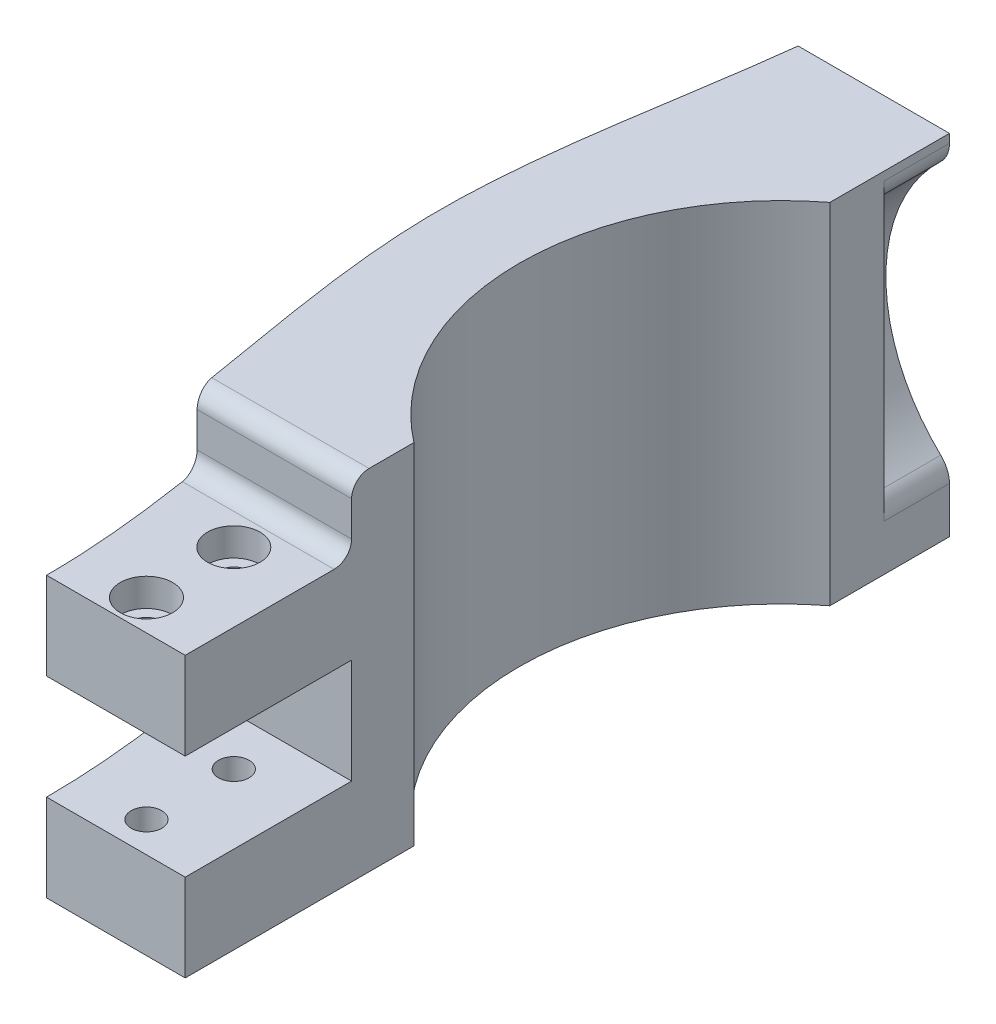
from build123d import *

# Parameters (mm, degrees)
BOSS_EXTRUDE1_DEPTH = 40
SKETCH3_W           = 12.7
SKETCH3_H           = 40
BOSS_EXTRUDE2_DEPTH = 27.178
SKETCH4_W           = 184.978795618
SKETCH4_H           = 131.733859804
CUT_EXTRUDE2_DEPTH  = 51
SKETCH5_W           = 144.166334374
SKETCH5_H           = 140.012963834
CUT_EXTRUDE3_DEPTH  = 18.25
SKETCH6_R           = 20
CUT_EXTRUDE4_DEPTH  = 20
FILLET4_R           = 3.175
SKETCH7_W           = 96.652193462
SKETCH7_H           = 93.586405028
CUT_EXTRUDE5_DEPTH  = 27.178
CUT_EXTRUDE6_DEPTH  = 41
CUT_EXTRUDE7_DEPTH  = 8
FILLET5_R           = 2
SKETCH10_R          = 1.75
CUT_EXTRUDE8_DEPTH  = 33.0000001
SKETCH11_W          = 9.551786503
SKETCH11_H          = 12
SKETCH11_W_2        = 7.9375
CUT_EXTRUDE9_DEPTH  = 19.05
SKETCH14_R          = 3
CUT_EXTRUDE10_DEPTH = 3.2
SKETCH15_W          = 61.098487026
SKETCH15_H          = 49.743772834
CUT_EXTRUDE11_DEPTH = 12.5


with BuildPart() as part:
    # Sketch1 → Boss-Extrude1 (new body)
    with BuildSketch(Plane(origin=(0, 0, 0), x_dir=(1, 0, 0), z_dir=(0, 1, 0))):
        with BuildLine():
            Line((-50, -50), (0, -50))
            Line((0, -50), (0, -30))
            ThreePointArc((0, -30), (-30, 0), (0, 30))
            Line((0, 30), (0, 50))
            Line((0, 50), (-50, 50))
            Line((-50, 50), (-50, -50))
        make_face()
        with BuildLine():
            Line((0, -30), (0, -50))
            Line((0, -50), (50, -50))
            Line((50, -50), (50, 50))
            Line((50, 50), (0, 50))
            Line((0, 50), (0, 30))
            ThreePointArc((0, 30), (21.213203436, 21.213203436), (30, 0))
            ThreePointArc((30, 0), (21.213203436, -21.213203436), (0, -30))
        make_face()
    extrude(amount=BOSS_EXTRUDE1_DEPTH)

    # Sketch3 → Boss-Extrude2 (add)
    with BuildSketch(Plane.XY.offset(50)):
        with Locations((-24.6, 20)):
            Rectangle(SKETCH3_W, SKETCH3_H)
    extrude(amount=BOSS_EXTRUDE2_DEPTH)

    # Sketch4 → Cut-Extrude2 (cut, through all)
    with BuildSketch(Plane(origin=(0, 0, 0), x_dir=(0, 0, -1), z_dir=(1, 0, 0))):
        Rectangle(SKETCH4_W, SKETCH4_H)
    extrude(amount=CUT_EXTRUDE2_DEPTH, mode=Mode.SUBTRACT)

    # Sketch5 → Cut-Extrude3 (cut)
    with BuildSketch(Plane(origin=(0, 0, 0), x_dir=(0, 0, -1), z_dir=(1, 0, 0))):
        Rectangle(SKETCH5_W, SKETCH5_H)
    extrude(amount=-CUT_EXTRUDE3_DEPTH, mode=Mode.SUBTRACT)

    # Sketch6 → Cut-Extrude4 (cut)
    with BuildSketch(Plane(origin=(0, 0, -50), x_dir=(-1, 0, 0), z_dir=(0, 0, -1))):
        with Locations((5.529693955, 22.14995336)):
            Circle(SKETCH6_R)
    extrude(amount=-CUT_EXTRUDE4_DEPTH, mode=Mode.SUBTRACT)

    # Fillet4
    fillet4_edges = [part.edges().sort_by_distance(p)[0] for p in [
        (-18.25, 6.716424466, -40),
        (-18.25, 37.583482255, -40),
    ]]
    fillet(fillet4_edges, radius=FILLET4_R)

    # Sketch7 → Cut-Extrude5 (cut)
    with BuildSketch(Plane.XY.offset(77.178)):
        Rectangle(SKETCH7_W, SKETCH7_H)
    extrude(amount=-CUT_EXTRUDE5_DEPTH, mode=Mode.SUBTRACT)

    # Sketch8 → Cut-Extrude6 (cut, through all)
    with BuildSketch(Plane(origin=(0, 40, 0), x_dir=(1, 0, 0), z_dir=(0, 1, 0))):
        with BuildLine():
            Line((-34.76, 50), (-50, 50))
            Line((-50, 50), (-50, -50))
            Line((-50, -50), (-34.125, -50))
            add(Edge.make_bspline(
                [(-34.125, -50), (-34.125, -33.241229213), (-45.237036485, -0.093705418), (-34.76, 33.330216103), (-34.76, 50)],
                knots=[0, 0, 0, 0, 0.500369617, 1, 1, 1, 1], degree=3))
        make_face()
    extrude(amount=-CUT_EXTRUDE6_DEPTH, mode=Mode.SUBTRACT)

    # Sketch9 → Cut-Extrude7 (cut)
    with BuildSketch(Plane(origin=(0, 40, 0), x_dir=(1, 0, 0), z_dir=(0, 1, 0))):
        with BuildLine():
            Line((-18.25, -50), (-18.25, -30.95))
            Line((-18.25, -30.95), (-35.932995014, -30.95))
            add(Edge.make_bspline(
                [(-34.125, -50), (-34.125, -43.629466822), (-34.928437006, -37.283896996), (-35.932995014, -30.95)],
                knots=[0, 0, 0, 0, 0.190206149, 0.190206149, 0.190206149, 0.190206149], degree=3))
            Line((-34.125, -50), (-18.25, -50))
        make_face()
    extrude(amount=-CUT_EXTRUDE7_DEPTH, mode=Mode.SUBTRACT)

    # Fillet5
    fillet5_edges = [part.edges().sort_by_distance(p)[0] for p in [
        (-27.091497507, 32, 30.95),
        (-27.091497507, 40, 30.95),
    ]]
    fillet(fillet5_edges, radius=FILLET5_R)

    # Sketch10 → Cut-Extrude8 (cut, through all)
    with BuildSketch(Plane(origin=(0, 32, 0), x_dir=(1, 0, 0), z_dir=(0, 1, 0))):
        with Locations((-26.1875, -46.5)):
            Circle(SKETCH10_R)
        with Locations((-26.1875, -36.5)):
            Circle(SKETCH10_R)
    extrude(amount=-CUT_EXTRUDE8_DEPTH, mode=Mode.SUBTRACT)

    # Sketch11 → Cut-Extrude9 (cut)
    with BuildSketch(Plane.XY.offset(50)):
        with Locations((-38.900893252, 16)):
            Rectangle(SKETCH11_W, SKETCH11_H)
        with Locations((-30.15625, 16)):
            Rectangle(SKETCH11_W_2, SKETCH11_H)
        with Locations((-22.21875, 16)):
            Rectangle(SKETCH11_W_2, SKETCH11_H)
    extrude(amount=-CUT_EXTRUDE9_DEPTH, mode=Mode.SUBTRACT)

    # Sketch14 → Cut-Extrude10 (cut)
    with BuildSketch(Plane(origin=(0, 32, 0), x_dir=(1, 0, 0), z_dir=(0, 1, 0))):
        with Locations((-26.1875, -36.5)):
            Circle(SKETCH14_R)
        with Locations((-26.1875, -46.5)):
            Circle(SKETCH14_R)
    cut_extrude10 = extrude(amount=-CUT_EXTRUDE10_DEPTH, mode=Mode.SUBTRACT)

    # Mirror2: Cut-Extrude10 across plane
    add(cut_extrude10.mirror(Plane.ZX.offset(16)), mode=Mode.SUBTRACT)

    # Sketch15 → Cut-Extrude11 (cut)
    with BuildSketch(Plane(origin=(0, 0, -50), x_dir=(-1, 0, 0), z_dir=(0, 0, -1))):
        with Locations((30.549243513, 24.871886417)):
            Rectangle(SKETCH15_W, SKETCH15_H)
    extrude(amount=-CUT_EXTRUDE11_DEPTH, mode=Mode.SUBTRACT)


solid = part.part
